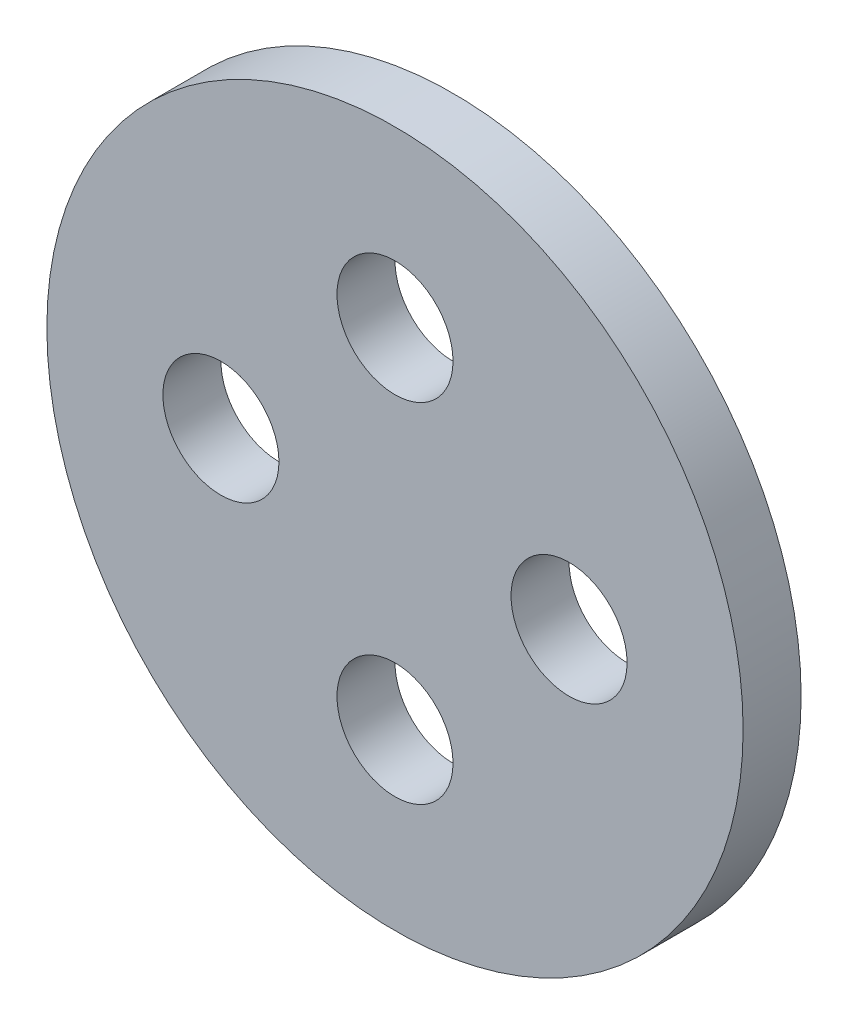
from build123d import *

# Parameters (mm, degrees)
SKETCH_1_R      = 6
SKETCH_1_R_2    = 1
EXTRUDE_1_DEPTH = 1


with BuildPart() as part:
    # ｽｹｯﾁ1 → ﾎﾞｽ - 押し出し1 (new body)
    with BuildSketch(Plane.XY):
        Circle(SKETCH_1_R)
        with Locations((0, 3)):
            Circle(SKETCH_1_R_2, mode=Mode.SUBTRACT)
        with Locations((3, 0)):
            Circle(SKETCH_1_R_2, mode=Mode.SUBTRACT)
        with Locations((0, -3)):
            Circle(SKETCH_1_R_2, mode=Mode.SUBTRACT)
        with Locations((-3, 0)):
            Circle(SKETCH_1_R_2, mode=Mode.SUBTRACT)
    extrude(amount=EXTRUDE_1_DEPTH)


solid = part.part
